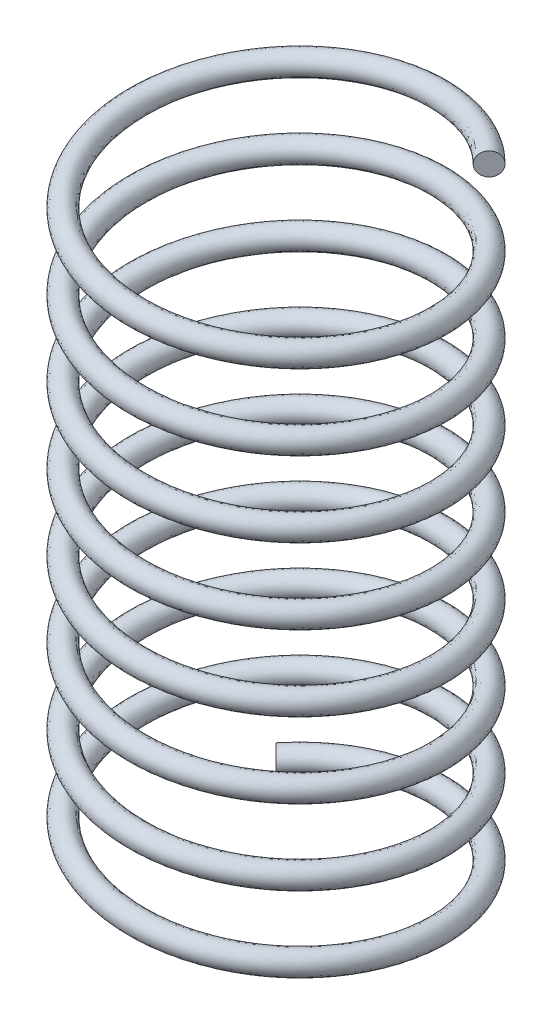
from build123d import *

# Parameters (mm, degrees)
SWEEP1_PITCH       = 20
SWEEP1_HEIGHT      = 165
SWEEP1_RADIUS      = 40
SWEEP1_START_ANGLE = -135
SKETCH2_R          = 3


with BuildPart() as part:
    # Sweep1: sweep along a helix
    with BuildLine() as sweep1_path:
        add(Helix(SWEEP1_PITCH, SWEEP1_HEIGHT, SWEEP1_RADIUS, center=(0, 0, 0), direction=(0, 1, 0), lefthand=True, mode=Mode.PRIVATE).rotate(Axis((0, 0, 0), (0, 1, 0)), SWEEP1_START_ANGLE))
    # Sketch2 → Sweep1 (sweep)
    with BuildSketch(Plane.XY):
        with Locations((-39.999732532, 77.5)):
            Circle(SKETCH2_R)
    sweep(path=sweep1_path.line, is_frenet=True)


solid = part.part
